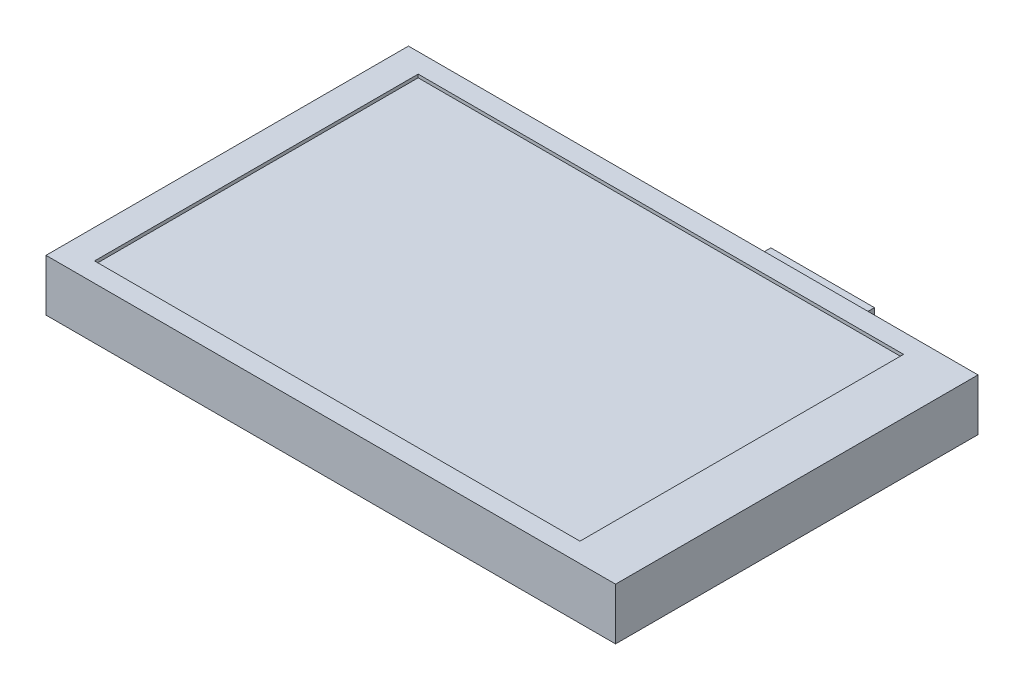
from build123d import *

# Parameters (mm, degrees)
SKETCH1_W           = 88
SKETCH1_H           = 56
BOSS_EXTRUDE1_DEPTH = 8
SKETCH2_W           = 75
SKETCH2_H           = 50
CUT_EXTRUDE1_DEPTH  = 0.5
SKETCH3_W           = 16
SKETCH3_H           = 9
BOSS_EXTRUDE2_DEPTH = 12


with BuildPart() as part:
    # Sketch1 → Boss-Extrude1 (new body)
    with BuildSketch(Plane(origin=(0, 0, 0), x_dir=(1, 0, 0), z_dir=(0, 1, 0))):
        Rectangle(SKETCH1_W, SKETCH1_H)
    extrude(amount=BOSS_EXTRUDE1_DEPTH)

    # Sketch2 → Cut-Extrude1 (cut)
    with BuildSketch(Plane(origin=(0, 8, 0), x_dir=(1, 0, 0), z_dir=(0, 1, 0))):
        with Locations((-2, 0)):
            Rectangle(SKETCH2_W, SKETCH2_H)
    extrude(amount=-CUT_EXTRUDE1_DEPTH, mode=Mode.SUBTRACT)


with BuildPart() as body_2:
    # Sketch3 → Boss-Extrude2 (new body)
    with BuildSketch(Plane(origin=(0, 0, 0), x_dir=(1, 0, 0), z_dir=(0, 1, 0))):
        with Locations((11, 32.5)):
            Rectangle(SKETCH3_W, SKETCH3_H)
    extrude(amount=-BOSS_EXTRUDE2_DEPTH)


solid = Compound([part.part, body_2.part])
